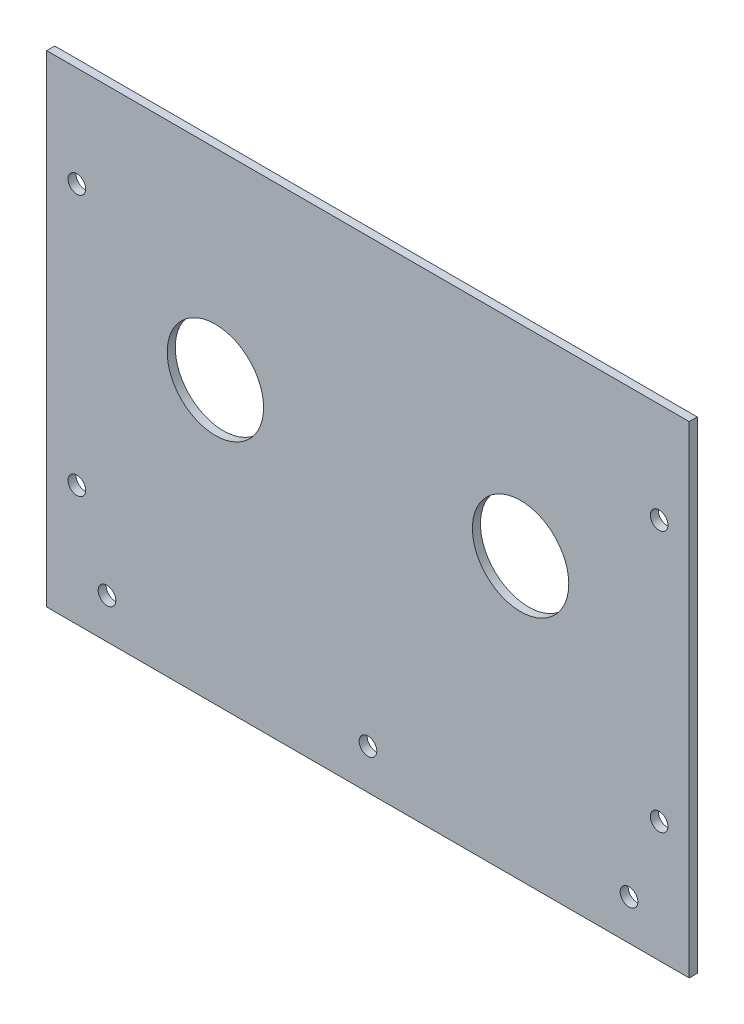
from build123d import *

# Parameters (mm, degrees)
SKETCH_1_W          = 160
SKETCH_1_H          = 120
EXTRUDE_1_DEPTH     = 2
SKETCH_2_R          = 2.2
SKETCH_2_R_2        = 12
CUT_EXTRUDE_1_DEPTH = 2
SKETCH_4_R          = 2.2
CUT_EXTRUDE_2_DEPTH = 105


with BuildPart() as part:
    # ｽｹｯﾁ1 → ﾎﾞｽ - 押し出し1 (new body)
    with BuildSketch(Plane.XY):
        Rectangle(SKETCH_1_W, SKETCH_1_H)
    extrude(amount=EXTRUDE_1_DEPTH)

    # ｽｹｯﾁ2 → ｶｯﾄ - 押し出し1 (cut)
    with BuildSketch(Plane.XY.offset(2)):
        with Locations((0, -50)):
            Circle(SKETCH_2_R)
        with Locations((-65, -50)):
            Circle(SKETCH_2_R)
        with Locations((-38, 10)):
            Circle(SKETCH_2_R_2)
        with Locations((38, 10)):
            Circle(SKETCH_2_R_2)
        with Locations((65, -50)):
            Circle(SKETCH_2_R)
    extrude(amount=-CUT_EXTRUDE_1_DEPTH, mode=Mode.SUBTRACT)

    # ｽｹｯﾁ4 → ｶｯﾄ - 押し出し2 (cut)
    with BuildSketch(Plane.XY.offset(2)):
        with Locations((72.5, 35)):
            Circle(SKETCH_4_R)
        with Locations((72.5, -30)):
            Circle(SKETCH_4_R)
        with Locations((-72.5, 35)):
            Circle(SKETCH_4_R)
        with Locations((-72.5, -30)):
            Circle(SKETCH_4_R)
    extrude(amount=-CUT_EXTRUDE_2_DEPTH, mode=Mode.SUBTRACT)


solid = part.part
